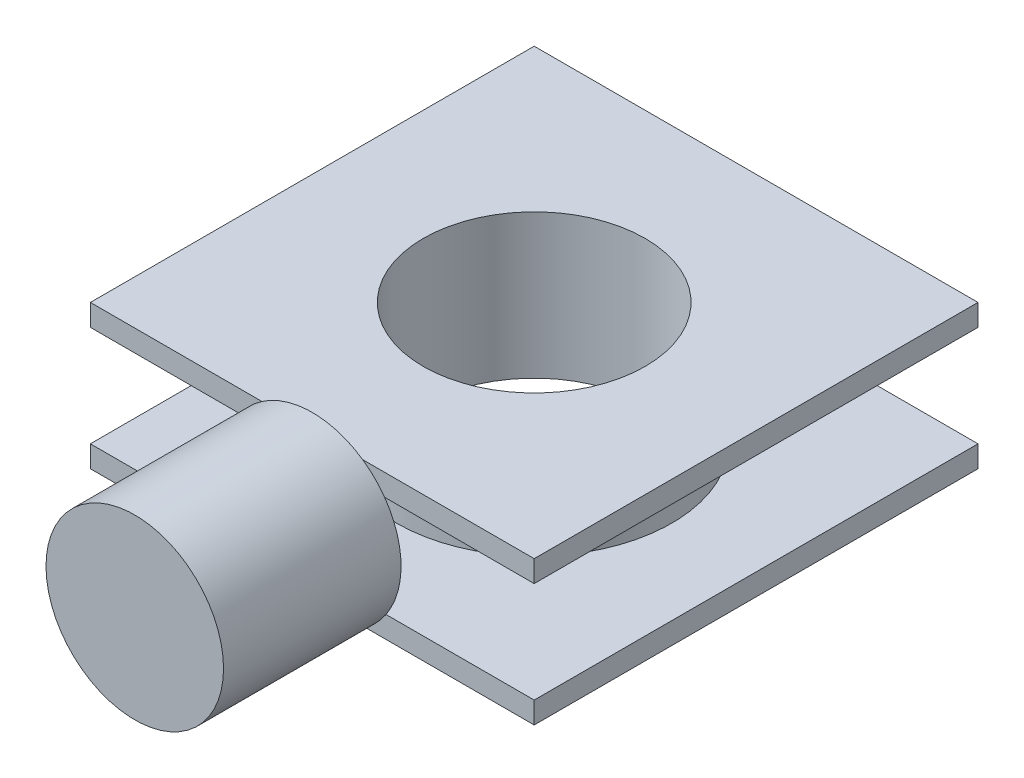
from build123d import *

# Parameters (mm, degrees)
SKETCH1_R                = 15.5
SKETCH1_R_2              = 12.5
BOSS_EXTRUDE1_DEPTH      = 15
BOSS_EXTRUDE2_DEPTH      = 50
BOSS_EXTRUDE2_DEPTH_BACK = 50
SKETCH2_W                = 100
SKETCH2_H                = 2.435831537
SKETCH2_H_2              = 2.435831538
SKETCH1_4_R              = 12.5
CUT_EXTRUDE1_DEPTH       = 20
SKETCH1_7_R              = 100
SKETCH1_7_W              = 50
SKETCH1_7_H              = 50
CUT_EXTRUDE2_DEPTH       = 20
SKETCH4_R                = 10
BOSS_EXTRUDE3_DEPTH      = 20


with BuildPart() as part:
    # Sketch1 → Boss-Extrude1 (new body)
    with BuildSketch(Plane(origin=(0, 0, 0), x_dir=(1, 0, 0), z_dir=(0, 1, 0))):
        Circle(SKETCH1_R)
        Circle(SKETCH1_R_2, mode=Mode.SUBTRACT)
    extrude(amount=BOSS_EXTRUDE1_DEPTH)

    # Sketch2 → Boss-Extrude2 (add, two sides: drawn at the far end of the back side and taken through both)
    with BuildSketch(Plane.XY.offset(-BOSS_EXTRUDE2_DEPTH_BACK)):
        with Locations((0, 1.217915769)):
            Rectangle(SKETCH2_W, SKETCH2_H)
        with Locations((0, 15.01290923)):
            Rectangle(SKETCH2_W, SKETCH2_H_2)
    extrude(amount=BOSS_EXTRUDE2_DEPTH + BOSS_EXTRUDE2_DEPTH_BACK)

    # Sketch1_4 → Cut-Extrude1 (cut)
    with BuildSketch(Plane(origin=(0, 0, 0), x_dir=(1, 0, 0), z_dir=(0, 1, 0))):
        Circle(SKETCH1_4_R)
    extrude(amount=CUT_EXTRUDE1_DEPTH, mode=Mode.SUBTRACT)

    # Sketch1_7 → Cut-Extrude2 (cut)
    with BuildSketch(Plane(origin=(0, 0, 0), x_dir=(1, 0, 0), z_dir=(0, 1, 0))):
        Circle(SKETCH1_7_R)
        Rectangle(SKETCH1_7_W, SKETCH1_7_H, mode=Mode.SUBTRACT)
    extrude(amount=CUT_EXTRUDE2_DEPTH, mode=Mode.SUBTRACT)

    # Sketch4 → Boss-Extrude3 (add)
    with BuildSketch(Plane.XY.offset(25)):
        with Locations((0, 8)):
            Circle(SKETCH4_R)
    extrude(amount=BOSS_EXTRUDE3_DEPTH)


solid = part.part
